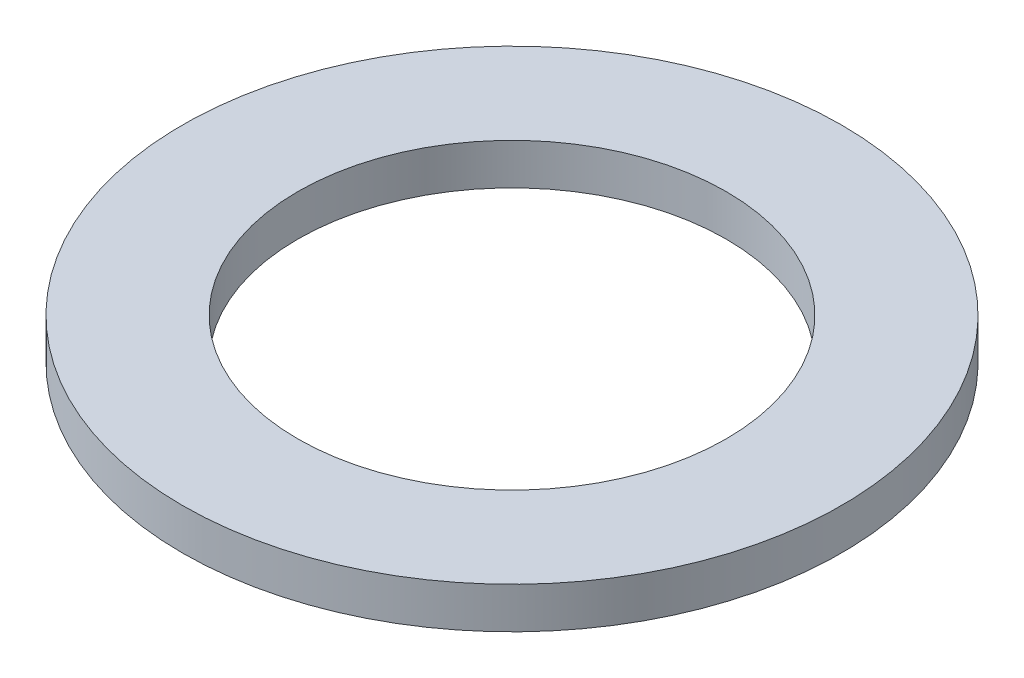
from build123d import *

# Parameters (mm, degrees)
SKETCH_1_R      = 4
SKETCH_1_R_2    = 2.6
EXTRUDE_1_DEPTH = 0.5


with BuildPart() as part:
    # Эскиз1 → Бобышка-Вытянуть1 (new body)
    with BuildSketch(Plane(origin=(0, 0, 0), x_dir=(1, 0, 0), z_dir=(0, 1, 0))):
        Circle(SKETCH_1_R)
        Circle(SKETCH_1_R_2, mode=Mode.SUBTRACT)
    extrude(amount=EXTRUDE_1_DEPTH)


solid = part.part
